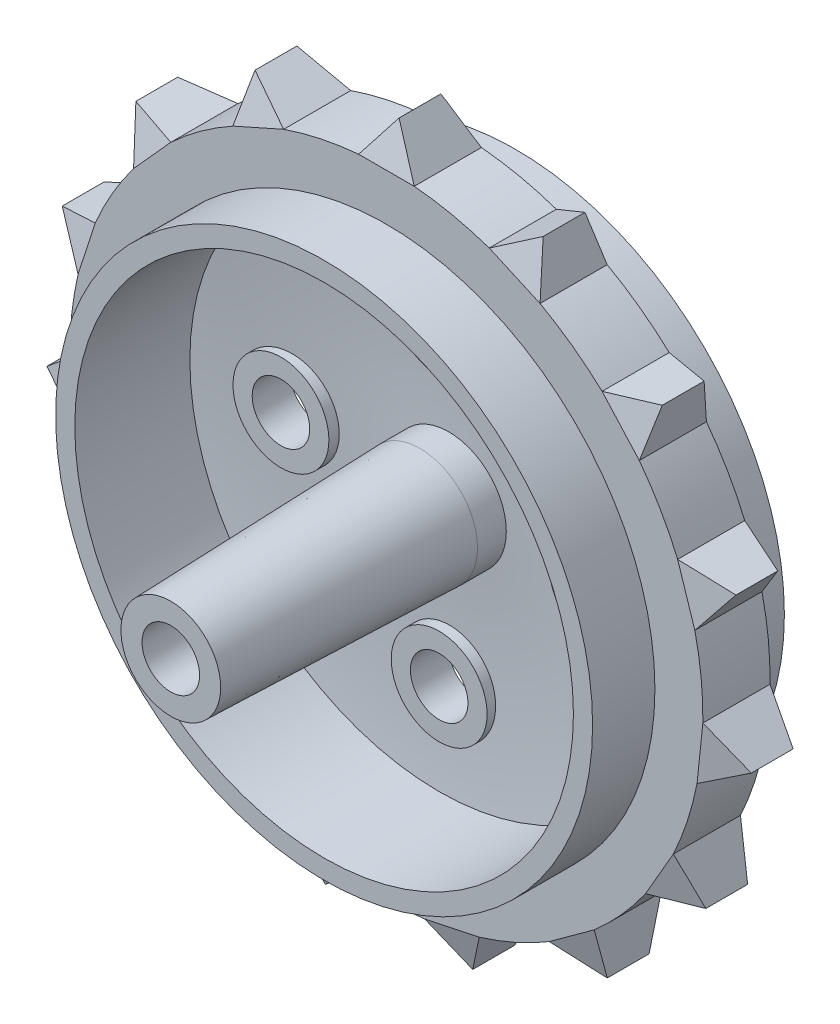
from build123d import *
from build123d.topology import SkipClean

# Parameters (mm, degrees)
SKETCH4_R                = 1.5
CUT_EXTRUDE1_DEPTH       = 14.25
SKETCH5_R                = 2.5
SKETCH5_R_2              = 1.5
BOSS_EXTRUDE3_DEPTH      = 0.5
BOSS_EXTRUDE3_DEPTH_BACK = 1.5
SKETCH6_R                = 3
BOSS_EXTRUDE4_DEPTH      = 1
FILLET2_R                = 0.25
SKETCH7_R                = 3
BOSS_EXTRUDE5_DEPTH      = 1
BOSS_EXTRUDE6_DEPTH      = 3.5
CUT_EXTRUDE2_START       = -1.45
CUT_EXTRUDE2_DEPTH       = 2.9
CIRPATTERN1_COUNT        = 15


with BuildPart() as part:
    # Sketch1 → Revolve1 (revolve)
    with BuildSketch(Plane(origin=(0, 0, 0), x_dir=(0, 0, -1), z_dir=(1, 0, 0)), mode=Mode.PRIVATE) as revolve1_sk:
        with BuildLine():
            Line((-5, 13), (1, 13))
            ThreePointArc((1, 13), (1.4724487, 8.011122435), (1.5, 3))
            Line((1.5, 3), (0, 3))
            Line((0, 3), (-12.993844697, 2.6))
            Line((-12.993844697, 2.6), (-12.993844697, 1.5))
            Line((-12.993844697, 1.5), (0, 1.5))
            Line((0, 1.5), (7, 1.5))
            Line((7, 1.5), (7, 3))
            Line((7, 3), (2.5, 3))
            ThreePointArc((2.5, 3), (2.4724487, 8.011122435), (2, 13))
            Line((2, 13), (5, 13))
            Line((5, 13), (5, 14))
            Line((5, 14), (1.75, 14))
            Line((1.75, 14), (1.75, 16.5))
            Line((1.75, 16.5), (-1.75, 16.5))
            Line((-1.75, 16.5), (-1.75, 14))
            Line((-1.75, 14), (-5, 14))
            Line((-5, 14), (-5, 13))
        make_face()
    revolve(revolve1_sk.sketch.rotate(Axis((0, 0, 19.383559074), (0, 0, -1)), 90), axis=Axis((0, 0, 19.383559074), (0, 0, -1)))

    # Sketch4 → Cut-Extrude1 (cut)
    with BuildSketch(Plane(origin=(0, 0, -7), x_dir=(-1, 0, 0), z_dir=(0, 0, -1))):
        with Locations(Location((0, 8.25, 0), (0, 0, 315.258783594))):
            Circle(SKETCH4_R)
        with Locations(Location((8.25, 0, 0), (0, 0, 315.207880729))):
            Circle(SKETCH4_R)
        with Locations(Location((0, -8.25, 0), (0, 0, 314.792119271))):
            Circle(SKETCH4_R)
        with Locations((-8.25, 0)):
            Circle(SKETCH4_R)
    extrude(amount=-CUT_EXTRUDE1_DEPTH, mode=Mode.SUBTRACT)

    # Sketch5 → Boss-Extrude3 (add, two sides)
    with BuildSketch(Plane(origin=(0, 0, -2.5), x_dir=(-1, 0, 0), z_dir=(0, 0, -1))) as boss_extrude3_sk:
        with Locations(Location((0, 8.25, 0), (0, 0, 315.130061921))):
            Circle(SKETCH5_R)
        with Locations((0, 8.25)):
            Circle(SKETCH5_R_2, mode=Mode.SUBTRACT)
        with Locations(Location((8.25, 0, 0), (0, 0, 315.060338271))):
            Circle(SKETCH5_R)
        with Locations((8.25, 0)):
            Circle(SKETCH5_R_2, mode=Mode.SUBTRACT)
        with Locations(Location((0, -8.25, 0), (0, 0, 314.939661729))):
            Circle(SKETCH5_R)
        with Locations((0, -8.25)):
            Circle(SKETCH5_R_2, mode=Mode.SUBTRACT)
        with Locations(Location((-8.25, 0, 0), (0, 0, 179.999999916))):
            Circle(SKETCH5_R)
        with Locations((-8.25, 0)):
            Circle(SKETCH5_R_2, mode=Mode.SUBTRACT)
    extrude(amount=BOSS_EXTRUDE3_DEPTH)
    extrude(boss_extrude3_sk.sketch, amount=-BOSS_EXTRUDE3_DEPTH_BACK)

    # Sketch6 → Boss-Extrude4 (add)
    with BuildSketch(Plane(origin=(0, 0, -7), x_dir=(-1, 0, 0), z_dir=(0, 0, -1))):
        with Locations(Location((0, 0, 0), (0, 0, 180))):
            Circle(SKETCH6_R)
    boss_extrude4 = extrude(amount=BOSS_EXTRUDE4_DEPTH)

    # Fillet2
    fillet2_edges = [part.edges().sort_by_distance(p)[0] for p in [
        (-3, 0, -8),
    ]]
    fillet(fillet2_edges, radius=FILLET2_R)

    # Sketch7 → Boss-Extrude5 (add)
    with SkipClean():  # the faces are left unmerged after this step: merging them gives an invalid solid
        with BuildSketch(Plane(origin=(0, 0, -3), x_dir=(-1, 0, 0), z_dir=(0, 0, -1))):
            with BuildLine():
                ThreePointArc((-1.792751449, 6.507575758), (0, 5.75), (1.792751449, 6.507575758))
                ThreePointArc((1.792751449, 6.507575758), (4.772970773, 4.772970773), (6.507575758, 1.792751449))
                ThreePointArc((6.507575758, 1.792751449), (5.75, 0), (6.507575758, -1.792751449))
                ThreePointArc((6.507575758, -1.792751449), (4.772970773, -4.772970773), (1.792751449, -6.507575758))
                ThreePointArc((1.792751449, -6.507575758), (0, -5.75), (-1.792751449, -6.507575758))
                ThreePointArc((-1.792751449, -6.507575758), (-4.772970773, -4.772970773), (-6.507575758, -1.792751449))
                ThreePointArc((-6.507575758, -1.792751449), (-5.75, 0), (-6.507575758, 1.792751449))
                ThreePointArc((-6.507575758, 1.792751449), (-4.772970773, 4.772970773), (-1.792751449, 6.507575758))
            make_face()
            with Locations(Location((0, 0, 0), (0, 0, 180))):
                Circle(SKETCH7_R, mode=Mode.SUBTRACT)
        extrude(amount=-BOSS_EXTRUDE5_DEPTH)

    # Sketch8 → Boss-Extrude6 (add)
    with SkipClean():  # the faces are left unmerged after this step: merging them gives an invalid solid
        with BuildSketch(Plane(origin=(0, 0, -1.75), x_dir=(-1, 0, 0), z_dir=(0, 0, -1))):
            Polygon((-1.45, 16.436164394), (1.45, 16.436164394), (0, 18.467489725), align=None)
        boss_extrude6 = extrude(amount=-BOSS_EXTRUDE6_DEPTH)

    # Sketch9 → Cut-Extrude2 (cut)
    with SkipClean():  # the faces are left unmerged after this step: merging them gives an invalid solid
        with BuildSketch(Plane(origin=(0, 0, 0), x_dir=(0, 0, -1), z_dir=(1, 0, 0)).offset(CUT_EXTRUDE2_START)):
            Polygon((-1.75, 16.436164394), (-1.089982391, 18.467489725), (-1.75, 18.467489725), align=None)
            Polygon((1.75, 18.467489725), (1.75, 16.436164394), (1.089982391, 18.467489725), align=None)
        cut_extrude2 = extrude(amount=CUT_EXTRUDE2_DEPTH, mode=Mode.SUBTRACT)

    # CirPattern1: Boss-Extrude4, Boss-Extrude6, Cut-Extrude2 ×15 about axis
    with SkipClean():  # the faces are left unmerged after this step: merging them gives an invalid solid
        cirpattern1_axis = Axis((0, 0, 0), (0, 0, 1))
        add([boss_extrude4.rotate(cirpattern1_axis, i * 360 / CIRPATTERN1_COUNT) for i in range(1, CIRPATTERN1_COUNT)])
        add([boss_extrude6.rotate(cirpattern1_axis, i * 360 / CIRPATTERN1_COUNT) for i in range(1, CIRPATTERN1_COUNT)])
        add([cut_extrude2.rotate(cirpattern1_axis, i * 360 / CIRPATTERN1_COUNT) for i in range(1, CIRPATTERN1_COUNT)], mode=Mode.SUBTRACT)


solid = part.part
